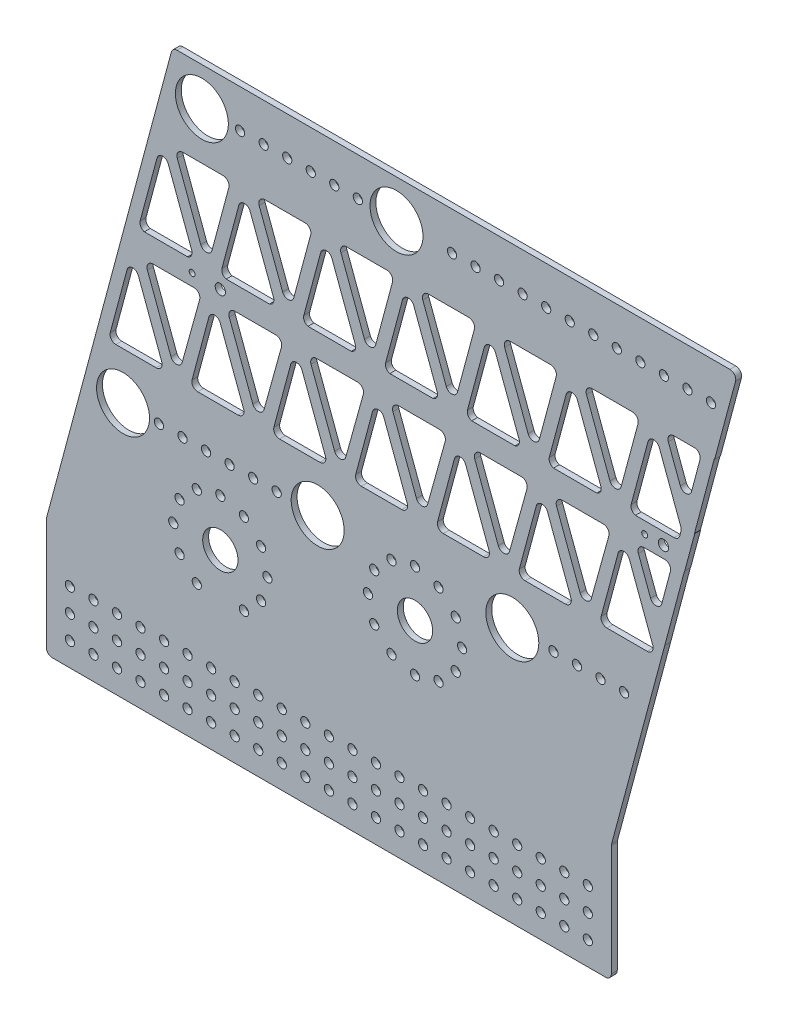
from build123d import *

# Parameters (mm, degrees)
SKETCH1_R           = 9.525
SKETCH1_R_2         = 14.2875
SKETCH1_R_3         = 2.4892
BOSS_EXTRUDE3_DEPTH = 3.175
CUT_EXTRUDE5_DEPTH  = 4.175
LPATTERN10_COUNT    = 7
LPATTERN10_PITCH    = 44.1452
BOSS_EXTRUDE4_DEPTH = 3.175
FILLET3_R           = 3.175
SKETCH2_R           = 2.4892
CUT_EXTRUDE6_DEPTH  = 4.175
FILLET2_R           = 3.175
SKETCH7_R           = 1.5875
SKETCH7_R_2         = 2.778125
CUT_EXTRUDE7_DEPTH  = 4.175


with BuildPart() as part:
    # Sketch1 → Boss-Extrude3 (new body)
    with BuildSketch(Plane.XY):
        Polygon((53.596537216, 200.025), (-14.462557661, -53.975), (-14.462557661, -117.475), (290.337442339, -117.475), (290.337442339, -53.975), (358.396537216, 200.025), align=None)
        with Locations((184.395313632, -2.294897399)):
            Circle(SKETCH1_R, mode=Mode.SUBTRACT)
        with Locations((26.895313632, 20.6375)):
            Circle(SKETCH1_R_2, mode=Mode.SUBTRACT)
        with Locations((131.895313632, 20.6375)):
            Circle(SKETCH1_R_2, mode=Mode.SUBTRACT)
        with Locations((236.895313632, 20.6375)):
            Circle(SKETCH1_R_2, mode=Mode.SUBTRACT)
        with Locations((69.43224793, 179.3875)):
            Circle(SKETCH1_R_2, mode=Mode.SUBTRACT)
        with Locations((174.41044793, 179.3875)):
            Circle(SKETCH1_R_2, mode=Mode.SUBTRACT)
        with Locations((79.395313632, -21.788906871)):
            Circle(SKETCH1_R, mode=Mode.SUBTRACT)
        with Locations((277.637442339, -79.375)):
            Circle(SKETCH1_R_3, mode=Mode.SUBTRACT)
        with Locations((-1.762557661, -104.775)):
            Circle(SKETCH1_R_3, mode=Mode.SUBTRACT)
        with Locations((10.937442339, -104.775)):
            Circle(SKETCH1_R_3, mode=Mode.SUBTRACT)
        with Locations((23.637442339, -104.775)):
            Circle(SKETCH1_R_3, mode=Mode.SUBTRACT)
        with Locations((-1.762557661, -92.075)):
            Circle(SKETCH1_R_3, mode=Mode.SUBTRACT)
        with Locations((-1.762557661, -79.375)):
            Circle(SKETCH1_R_3, mode=Mode.SUBTRACT)
        with Locations((10.937442339, -92.075)):
            Circle(SKETCH1_R_3, mode=Mode.SUBTRACT)
        with Locations((23.637442339, -92.075)):
            Circle(SKETCH1_R_3, mode=Mode.SUBTRACT)
        with Locations((10.937442339, -79.375)):
            Circle(SKETCH1_R_3, mode=Mode.SUBTRACT)
        with Locations((23.637442339, -79.375)):
            Circle(SKETCH1_R_3, mode=Mode.SUBTRACT)
        with Locations((36.337442339, -104.775)):
            Circle(SKETCH1_R_3, mode=Mode.SUBTRACT)
        with Locations((49.037442339, -104.775)):
            Circle(SKETCH1_R_3, mode=Mode.SUBTRACT)
        with Locations((61.737442339, -104.775)):
            Circle(SKETCH1_R_3, mode=Mode.SUBTRACT)
        with Locations((74.437442339, -104.775)):
            Circle(SKETCH1_R_3, mode=Mode.SUBTRACT)
        with Locations((36.337442339, -92.075)):
            Circle(SKETCH1_R_3, mode=Mode.SUBTRACT)
        with Locations((49.037442339, -92.075)):
            Circle(SKETCH1_R_3, mode=Mode.SUBTRACT)
        with Locations((36.337442339, -79.375)):
            Circle(SKETCH1_R_3, mode=Mode.SUBTRACT)
        with Locations((49.037442339, -79.375)):
            Circle(SKETCH1_R_3, mode=Mode.SUBTRACT)
        with Locations((61.737442339, -92.075)):
            Circle(SKETCH1_R_3, mode=Mode.SUBTRACT)
        with Locations((74.437442339, -92.075)):
            Circle(SKETCH1_R_3, mode=Mode.SUBTRACT)
        with Locations((61.737442339, -79.375)):
            Circle(SKETCH1_R_3, mode=Mode.SUBTRACT)
        with Locations((74.437442339, -79.375)):
            Circle(SKETCH1_R_3, mode=Mode.SUBTRACT)
        with Locations((87.137442339, -104.775)):
            Circle(SKETCH1_R_3, mode=Mode.SUBTRACT)
        with Locations((99.837442339, -104.775)):
            Circle(SKETCH1_R_3, mode=Mode.SUBTRACT)
        with Locations((112.537442339, -104.775)):
            Circle(SKETCH1_R_3, mode=Mode.SUBTRACT)
        with Locations((125.237442339, -104.775)):
            Circle(SKETCH1_R_3, mode=Mode.SUBTRACT)
        with Locations((87.137442339, -92.075)):
            Circle(SKETCH1_R_3, mode=Mode.SUBTRACT)
        with Locations((99.837442339, -92.075)):
            Circle(SKETCH1_R_3, mode=Mode.SUBTRACT)
        with Locations((87.137442339, -79.375)):
            Circle(SKETCH1_R_3, mode=Mode.SUBTRACT)
        with Locations((99.837442339, -79.375)):
            Circle(SKETCH1_R_3, mode=Mode.SUBTRACT)
        with Locations((112.537442339, -92.075)):
            Circle(SKETCH1_R_3, mode=Mode.SUBTRACT)
        with Locations((125.237442339, -92.075)):
            Circle(SKETCH1_R_3, mode=Mode.SUBTRACT)
        with Locations((112.537442339, -79.375)):
            Circle(SKETCH1_R_3, mode=Mode.SUBTRACT)
        with Locations((125.237442339, -79.375)):
            Circle(SKETCH1_R_3, mode=Mode.SUBTRACT)
        with Locations((137.937442339, -104.775)):
            Circle(SKETCH1_R_3, mode=Mode.SUBTRACT)
        with Locations((150.637442339, -104.775)):
            Circle(SKETCH1_R_3, mode=Mode.SUBTRACT)
        with Locations((163.337442339, -104.775)):
            Circle(SKETCH1_R_3, mode=Mode.SUBTRACT)
        with Locations((137.937442339, -92.075)):
            Circle(SKETCH1_R_3, mode=Mode.SUBTRACT)
        with Locations((137.937442339, -79.375)):
            Circle(SKETCH1_R_3, mode=Mode.SUBTRACT)
        with Locations((150.637442339, -92.075)):
            Circle(SKETCH1_R_3, mode=Mode.SUBTRACT)
        with Locations((163.337442339, -92.075)):
            Circle(SKETCH1_R_3, mode=Mode.SUBTRACT)
        with Locations((150.637442339, -79.375)):
            Circle(SKETCH1_R_3, mode=Mode.SUBTRACT)
        with Locations((163.337442339, -79.375)):
            Circle(SKETCH1_R_3, mode=Mode.SUBTRACT)
        with Locations((176.037442339, -104.775)):
            Circle(SKETCH1_R_3, mode=Mode.SUBTRACT)
        with Locations((188.737442339, -104.775)):
            Circle(SKETCH1_R_3, mode=Mode.SUBTRACT)
        with Locations((201.437442339, -104.775)):
            Circle(SKETCH1_R_3, mode=Mode.SUBTRACT)
        with Locations((214.137442339, -104.775)):
            Circle(SKETCH1_R_3, mode=Mode.SUBTRACT)
        with Locations((176.037442339, -92.075)):
            Circle(SKETCH1_R_3, mode=Mode.SUBTRACT)
        with Locations((188.737442339, -92.075)):
            Circle(SKETCH1_R_3, mode=Mode.SUBTRACT)
        with Locations((176.037442339, -79.375)):
            Circle(SKETCH1_R_3, mode=Mode.SUBTRACT)
        with Locations((188.737442339, -79.375)):
            Circle(SKETCH1_R_3, mode=Mode.SUBTRACT)
        with Locations((201.437442339, -92.075)):
            Circle(SKETCH1_R_3, mode=Mode.SUBTRACT)
        with Locations((214.137442339, -92.075)):
            Circle(SKETCH1_R_3, mode=Mode.SUBTRACT)
        with Locations((201.437442339, -79.375)):
            Circle(SKETCH1_R_3, mode=Mode.SUBTRACT)
        with Locations((214.137442339, -79.375)):
            Circle(SKETCH1_R_3, mode=Mode.SUBTRACT)
        with Locations((226.837442339, -104.775)):
            Circle(SKETCH1_R_3, mode=Mode.SUBTRACT)
        with Locations((239.537442339, -104.775)):
            Circle(SKETCH1_R_3, mode=Mode.SUBTRACT)
        with Locations((252.237442339, -104.775)):
            Circle(SKETCH1_R_3, mode=Mode.SUBTRACT)
        with Locations((264.937442339, -104.775)):
            Circle(SKETCH1_R_3, mode=Mode.SUBTRACT)
        with Locations((226.837442339, -92.075)):
            Circle(SKETCH1_R_3, mode=Mode.SUBTRACT)
        with Locations((239.537442339, -92.075)):
            Circle(SKETCH1_R_3, mode=Mode.SUBTRACT)
        with Locations((226.837442339, -79.375)):
            Circle(SKETCH1_R_3, mode=Mode.SUBTRACT)
        with Locations((239.537442339, -79.375)):
            Circle(SKETCH1_R_3, mode=Mode.SUBTRACT)
        with Locations((252.237442339, -92.075)):
            Circle(SKETCH1_R_3, mode=Mode.SUBTRACT)
        with Locations((264.937442339, -92.075)):
            Circle(SKETCH1_R_3, mode=Mode.SUBTRACT)
        with Locations((252.237442339, -79.375)):
            Circle(SKETCH1_R_3, mode=Mode.SUBTRACT)
        with Locations((264.937442339, -79.375)):
            Circle(SKETCH1_R_3, mode=Mode.SUBTRACT)
        with Locations((277.637442339, -104.775)):
            Circle(SKETCH1_R_3, mode=Mode.SUBTRACT)
        with Locations((277.637442339, -92.075)):
            Circle(SKETCH1_R_3, mode=Mode.SUBTRACT)
    extrude(amount=BOSS_EXTRUDE3_DEPTH)

    # Sketch4 → Cut-Extrude5 (cut, through all)
    with BuildSketch(Plane.XY.offset(3.175)):
        with BuildLine():
            ThreePointArc((36.118291703, 110.260783732), (36.445130521, 107.834926576), (38.400524735, 106.3625))
            Line((38.400524735, 106.3625), (61.743060773, 106.3625))
            ThreePointArc((61.743060773, 106.3625), (63.771076782, 107.965968282), (63.93419974, 110.546152454))
            Line((63.93419974, 110.546152454), (51.276698104, 144.56704793))
            ThreePointArc((51.276698104, 144.56704793), (48.151199972, 146.63139396), (45.234163172, 144.281679208))
            Line((45.234163172, 144.281679208), (36.118291703, 110.260783732))
        make_face()
        with BuildLine():
            Line((56.17686188, 149.606914073), (68.834363516, 115.586018597))
            ThreePointArc((68.834363516, 115.586018597), (71.959861649, 113.521672567), (74.876898448, 115.871387319))
            Line((74.876898448, 115.871387319), (83.992769917, 149.892282795))
            ThreePointArc((83.992769917, 149.892282795), (83.444852274, 152.646850801), (80.925955419, 153.889033264))
            Line((80.925955419, 153.889033264), (59.152582314, 153.889033264))
            ThreePointArc((59.152582314, 153.889033264), (56.545310902, 152.525872325), (56.17686188, 149.606914073))
        make_face()
        with BuildLine():
            Line((40.039210929, 89.38038081), (52.747453083, 55.223104719))
            ThreePointArc((52.747453083, 55.223104719), (55.859327638, 53.158144614), (58.782815694, 55.482158613))
            Line((58.782815694, 55.482158613), (68.250458896, 89.639434704))
            ThreePointArc((68.250458896, 89.639434704), (67.717992249, 92.409480448), (65.190816719, 93.6625))
            Line((65.190816719, 93.6625), (43.014931363, 93.6625))
            ThreePointArc((43.014931363, 93.6625), (40.407659951, 92.299339062), (40.039210929, 89.38038081))
        make_face()
        with BuildLine():
            ThreePointArc((29.096512221, 84.055145945), (32.013549021, 86.404860696), (35.139047153, 84.340514667))
            Line((35.139047153, 84.340514667), (47.796548789, 50.31961919))
            ThreePointArc((47.796548789, 50.31961919), (47.428099768, 47.400660938), (44.820828356, 46.0375))
            Line((44.820828356, 46.0375), (23.047455251, 46.0375))
            ThreePointArc((23.047455251, 46.0375), (20.528558395, 47.279682463), (19.980640752, 50.034250468))
            Line((19.980640752, 50.034250468), (29.096512221, 84.055145945))
        make_face()
    cut_extrude5 = extrude(amount=-CUT_EXTRUDE5_DEPTH, mode=Mode.SUBTRACT)

    # LPattern10: Cut-Extrude5 ×7
    with Locations(*[(i * LPATTERN10_PITCH, 0, 0) for i in range(1, LPATTERN10_COUNT)]):
        add(cut_extrude5, mode=Mode.SUBTRACT)

    # Sketch6 → Boss-Extrude4 (add)
    with BuildSketch(Plane.XY.offset(3.175)):
        Polygon((319.137718222, 53.509092868), (345.797155419, 153.889033264), (339.659914422, 155.518994292), (313.000477225, 55.139053896), align=None)
    extrude(amount=-BOSS_EXTRUDE4_DEPTH)

    # Fillet3
    fillet3_edges = [part.edges().sort_by_distance(p)[0] for p in [
        (326.604671839, 106.3625, 1.5875),
        (323.231738451, 93.6625, 1.5875),
        (339.227020724, 153.889033264, 1.5875),
        (330.991624876, 122.880556293, 1.5875),
        (328.169628413, 112.25498177, 1.5875),
        (314.937043846, 62.430747284, 1.5875),
    ]]
    fillet(fillet3_edges, radius=FILLET3_R)

    # Sketch2 → Cut-Extrude6 (cut, through all)
    with BuildSketch(Plane.XY.offset(3.175)):
        with Locations((79.395313632, 3.611093129)):
            Circle(SKETCH2_R)
        with Locations((92.095313632, 0.208138385)):
            Circle(SKETCH2_R)
        with Locations((101.392358888, -9.088906871)):
            Circle(SKETCH2_R)
        with Locations((104.795313632, -21.788906871)):
            Circle(SKETCH2_R)
        with Locations((101.392358888, -34.488906871)):
            Circle(SKETCH2_R)
        with Locations((92.095313632, -43.785952127)):
            Circle(SKETCH2_R)
        with Locations((66.695313632, -43.785952127)):
            Circle(SKETCH2_R)
        with Locations((57.398268376, -34.488906871)):
            Circle(SKETCH2_R)
        with Locations((53.995313632, -21.788906871)):
            Circle(SKETCH2_R)
        with Locations((57.398268376, -9.088906871)):
            Circle(SKETCH2_R)
        with Locations((66.695313632, 0.208138385)):
            Circle(SKETCH2_R)
        with Locations((184.395313632, -27.694897399)):
            Circle(SKETCH2_R)
        with Locations((171.695313632, -24.291942655)):
            Circle(SKETCH2_R)
        with Locations((162.398268376, -14.994897399)):
            Circle(SKETCH2_R)
        with Locations((158.995313632, -2.294897399)):
            Circle(SKETCH2_R)
        with Locations((162.398268376, 10.405102601)):
            Circle(SKETCH2_R)
        with Locations((171.695313632, 19.702147858)):
            Circle(SKETCH2_R)
        with Locations((197.095313632, 19.702147858)):
            Circle(SKETCH2_R)
        with Locations((206.392358888, 10.405102601)):
            Circle(SKETCH2_R)
        with Locations((209.795313632, -2.294897399)):
            Circle(SKETCH2_R)
        with Locations((206.392358888, -14.994897399)):
            Circle(SKETCH2_R)
        with Locations((197.095313632, -24.291942655)):
            Circle(SKETCH2_R)
        with Locations((184.395313632, 23.105102601)):
            Circle(SKETCH2_R)
        with Locations((58.987008713, 20.6375)):
            Circle(SKETCH2_R)
        with Locations((46.287008713, 20.6375)):
            Circle(SKETCH2_R)
        with Locations((71.687008713, 20.6375)):
            Circle(SKETCH2_R)
        with Locations((84.387008713, 20.6375)):
            Circle(SKETCH2_R)
        with Locations((97.087008713, 20.6375)):
            Circle(SKETCH2_R)
        with Locations((109.787008713, 20.6375)):
            Circle(SKETCH2_R)
        with Locations((90.06974793, 179.3875)):
            Circle(SKETCH2_R)
        with Locations((102.76974793, 179.3875)):
            Circle(SKETCH2_R)
        with Locations((115.46974793, 179.3875)):
            Circle(SKETCH2_R)
        with Locations((128.16974793, 179.3875)):
            Circle(SKETCH2_R)
        with Locations((140.86974793, 179.3875)):
            Circle(SKETCH2_R)
        with Locations((153.56974793, 179.3875)):
            Circle(SKETCH2_R)
        with Locations((204.36974793, 179.3875)):
            Circle(SKETCH2_R)
        with Locations((217.06974793, 179.3875)):
            Circle(SKETCH2_R)
        with Locations((229.76974793, 179.3875)):
            Circle(SKETCH2_R)
        with Locations((242.46974793, 179.3875)):
            Circle(SKETCH2_R)
        with Locations((255.16974793, 179.3875)):
            Circle(SKETCH2_R)
        with Locations((267.86974793, 179.3875)):
            Circle(SKETCH2_R)
        with Locations((280.56974793, 179.3875)):
            Circle(SKETCH2_R)
        with Locations((293.26974793, 179.3875)):
            Circle(SKETCH2_R)
        with Locations((305.96974793, 179.3875)):
            Circle(SKETCH2_R)
        with Locations((318.66974793, 179.3875)):
            Circle(SKETCH2_R)
        with Locations((331.36974793, 179.3875)):
            Circle(SKETCH2_R)
        with Locations((344.06974793, 179.3875)):
            Circle(SKETCH2_R)
        with Locations((297.181793968, 20.6375)):
            Circle(SKETCH2_R)
        with Locations((284.481793968, 20.6375)):
            Circle(SKETCH2_R)
        with Locations((271.781793968, 20.6375)):
            Circle(SKETCH2_R)
        with Locations((259.081793968, 20.6375)):
            Circle(SKETCH2_R)
    extrude(amount=-CUT_EXTRUDE6_DEPTH, mode=Mode.SUBTRACT)

    # Fillet2
    fillet2_edges = [part.edges().sort_by_distance(p)[0] for p in [
        (290.337442339, -117.475, 1.5875),
        (-14.462557661, -117.475, 1.5875),
        (-14.462557661, -53.975, 1.5875),
        (53.596537216, 200.025, 1.5875),
        (358.396537216, 200.025, 1.5875),
        (290.337442339, -53.975, 1.5875),
    ]]
    fillet(fillet2_edges, radius=FILLET2_R)

    # Sketch7 → Cut-Extrude7 (cut, through all)
    with BuildSketch(Plane.XY.offset(3.175)):
        with Locations((308.290261117, 100.0125)):
            Circle(SKETCH7_R)
        with Locations((318.450261117, 100.0125)):
            Circle(SKETCH7_R_2)
        with Locations((79.395313632, 100.0125)):
            Circle(SKETCH7_R_2)
        with Locations((64.155313632, 100.0125)):
            Circle(SKETCH7_R)
    extrude(amount=-CUT_EXTRUDE7_DEPTH, mode=Mode.SUBTRACT)


solid = part.part
